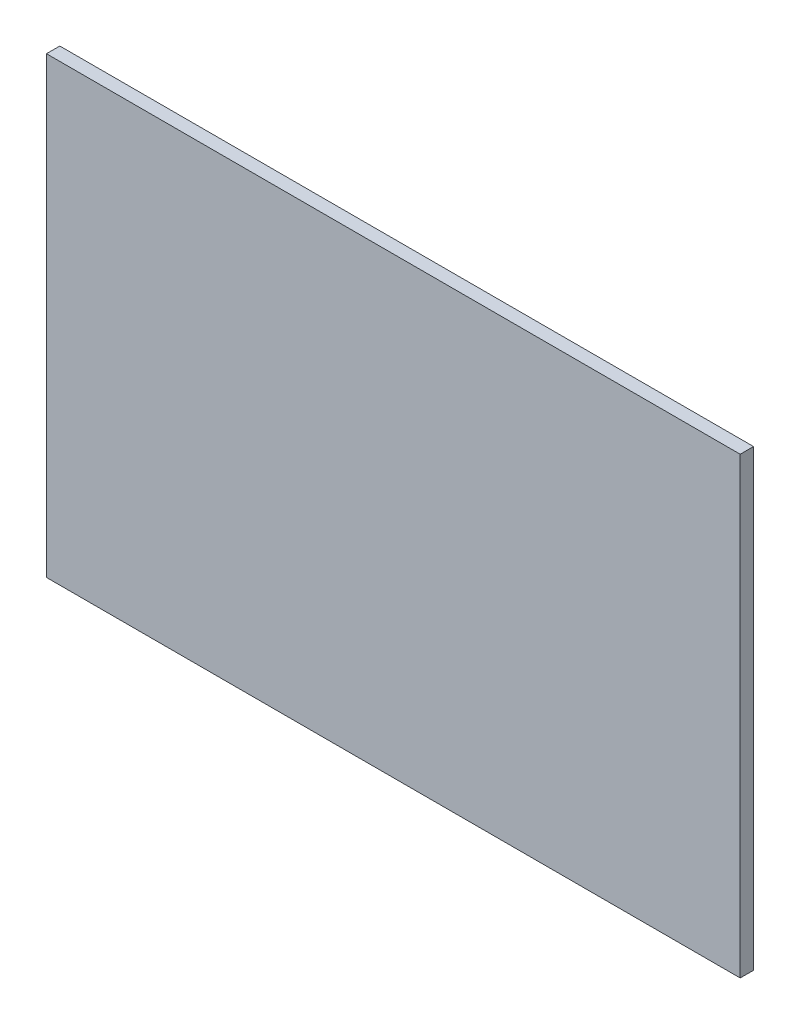
from build123d import *

# Parameters (mm, degrees)
SKETCH1_W           = 330.2
SKETCH1_H           = 215.9
BOSS_EXTRUDE1_DEPTH = 3.175


with BuildPart() as part:
    # Sketch1 → Boss-Extrude1 (new body, symmetric)
    with BuildSketch(Plane.XY):
        Rectangle(SKETCH1_W, SKETCH1_H)
    extrude(amount=BOSS_EXTRUDE1_DEPTH, both=True)


solid = part.part
